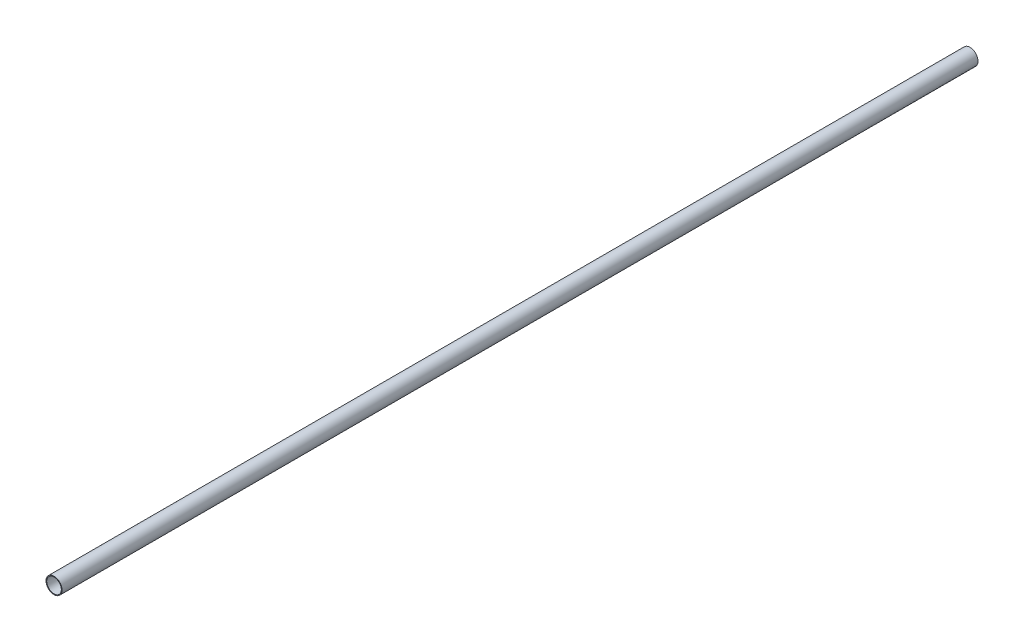
from build123d import *

# Parameters (mm, degrees)
SKETCH1_R           = 2.75
SKETCH1_R_2         = 2.5
BOSS_EXTRUDE3_DEPTH = 314


with BuildPart() as part:
    # Sketch1 → Boss-Extrude3 (new body)
    with BuildSketch(Plane.XY):
        Circle(SKETCH1_R)
        Circle(SKETCH1_R_2, mode=Mode.SUBTRACT)
    extrude(amount=BOSS_EXTRUDE3_DEPTH)


solid = part.part
